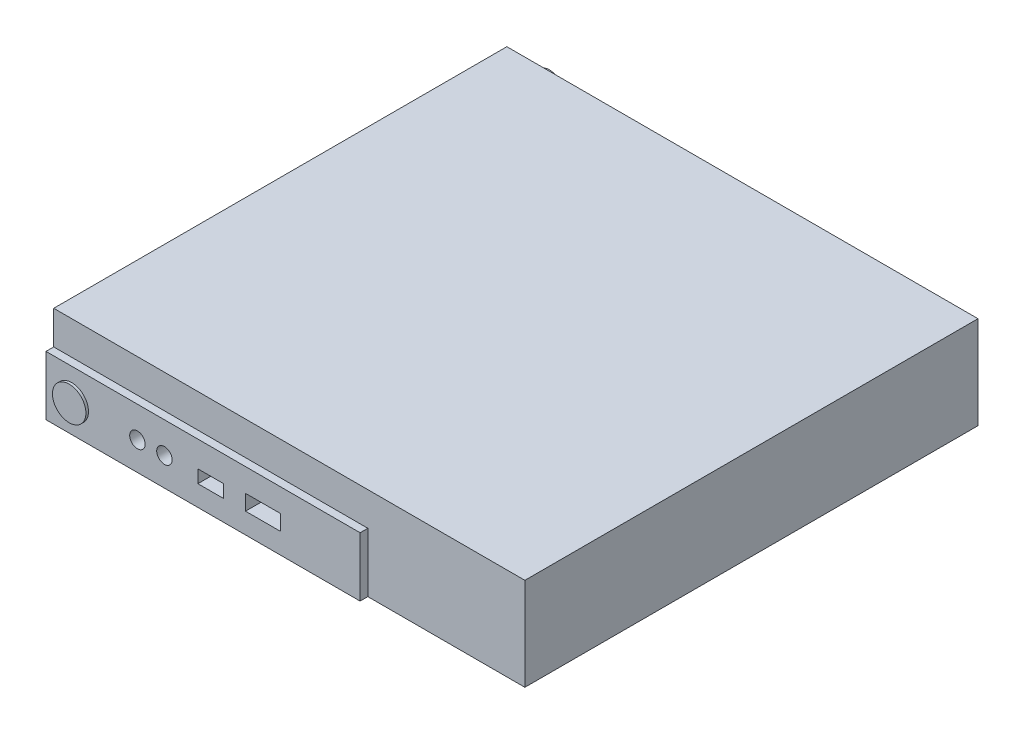
from build123d import *

# Parameters (mm, degrees)
SKETCH_1_W          = 183
SKETCH_1_H          = 179
EXTRUDE_1_DEPTH     = 36
CUT_EXTRUDE_1_DEPTH = 3
SKETCH_3_R          = 3
SKETCH_3_W          = 10
SKETCH_3_H          = 5
SKETCH_3_W_2        = 13.5
SKETCH_3_H_2        = 6
CUT_EXTRUDE_2_DEPTH = 10
SKETCH_4_R          = 6.5
EXTRUDE_2_DEPTH     = 1
SKETCH_5_R          = 2.5
SKETCH_5_W          = 17
SKETCH_5_H          = 6
SKETCH_5_W_2        = 13
SKETCH_5_W_3        = 15
SKETCH_5_H_2        = 11
CUT_EXTRUDE_3_DEPTH = 10
SKETCH_6_R          = 5
EXTRUDE_3_DEPTH     = 7.5


with BuildPart() as part:
    # 草图1 → 凸台-拉伸1 (new body)
    with BuildSketch(Plane(origin=(0, 0, 0), x_dir=(1, 0, 0), z_dir=(0, 1, 0))):
        Rectangle(SKETCH_1_W, SKETCH_1_H)
    extrude(amount=EXTRUDE_1_DEPTH)

    # 草图2 → 切除-拉伸1 (cut)
    with BuildSketch(Plane.XY.offset(89.5)):
        Polygon((-91.5, 36), (-91.5, 23), (30.5, 23), (30.5, 0), (91.5, 0), (91.5, 36), align=None)
    extrude(amount=-CUT_EXTRUDE_1_DEPTH, mode=Mode.SUBTRACT)

    # 草图3 → 切除-拉伸2 (cut)
    with BuildSketch(Plane.XY.offset(89.5)):
        with Locations((-56, 11)):
            Circle(SKETCH_3_R)
        with Locations((-45.5, 11)):
            Circle(SKETCH_3_R)
        with Locations((-27.5, 10.5)):
            Rectangle(SKETCH_3_W, SKETCH_3_H)
        with Locations((-7.25, 11)):
            Rectangle(SKETCH_3_W_2, SKETCH_3_H_2)
    extrude(amount=-CUT_EXTRUDE_2_DEPTH, mode=Mode.SUBTRACT)

    # 草图4 → 凸台-拉伸2 (add)
    with BuildSketch(Plane.XY.offset(89.5)):
        with Locations((-81.5, 11)):
            Circle(SKETCH_4_R)
    extrude(amount=EXTRUDE_2_DEPTH)

    # 草图5 → 切除-拉伸3 (cut)
    with BuildSketch(Plane(origin=(0, 0, -89.5), x_dir=(-1, 0, 0), z_dir=(0, 0, -1))):
        with Locations((-78, 11)):
            Circle(SKETCH_5_R)
        with Locations((-60, 11)):
            Rectangle(SKETCH_5_W, SKETCH_5_H)
        with Locations((-37, 11)):
            Rectangle(SKETCH_5_W, SKETCH_5_H)
        with Locations((16, 19.5)):
            Rectangle(SKETCH_5_W_2, SKETCH_5_H)
        with Locations((35, 19.5)):
            Rectangle(SKETCH_5_W_2, SKETCH_5_H)
        with Locations((16, 11)):
            Rectangle(SKETCH_5_W_2, SKETCH_5_H)
        with Locations((35, 11)):
            Rectangle(SKETCH_5_W_2, SKETCH_5_H)
        with Locations((59, 9.5)):
            Rectangle(SKETCH_5_W_3, SKETCH_5_H_2)
    extrude(amount=-CUT_EXTRUDE_3_DEPTH, mode=Mode.SUBTRACT)

    # 草图6 → 凸台-拉伸3 (add)
    with BuildSketch(Plane(origin=(0, 0, -89.5), x_dir=(-1, 0, 0), z_dir=(0, 0, -1))):
        with Locations((82.5, 24)):
            Circle(SKETCH_6_R)
    extrude(amount=EXTRUDE_3_DEPTH)


solid = part.part
